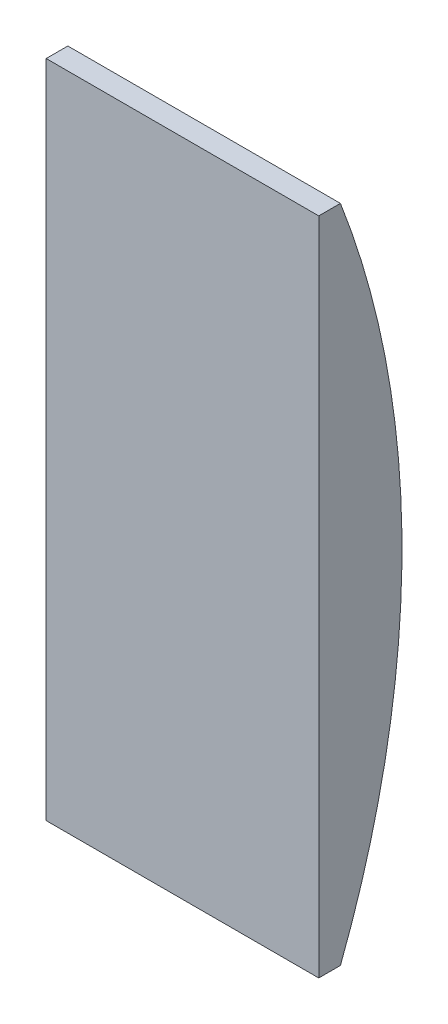
from build123d import *

# Parameters (mm, degrees)
BOSS_EXTRUDE1_DEPTH = 39.1795


with BuildPart() as part:
    # Sketch1 → Boss-Extrude1 (new body)
    with BuildSketch(Plane(origin=(0, 0, 0), x_dir=(0, 0, -1), z_dir=(1, 0, 0))):
        with BuildLine():
            Line((0, 94.869), (3.11404, 94.869))
            ThreePointArc((3.11404, 94.869), (11.96086, 47.4345), (3.11404, 0))
            Line((3.11404, 0), (0, 0))
            Line((0, 0), (0, 94.869))
        make_face()
    extrude(amount=BOSS_EXTRUDE1_DEPTH)


solid = part.part
